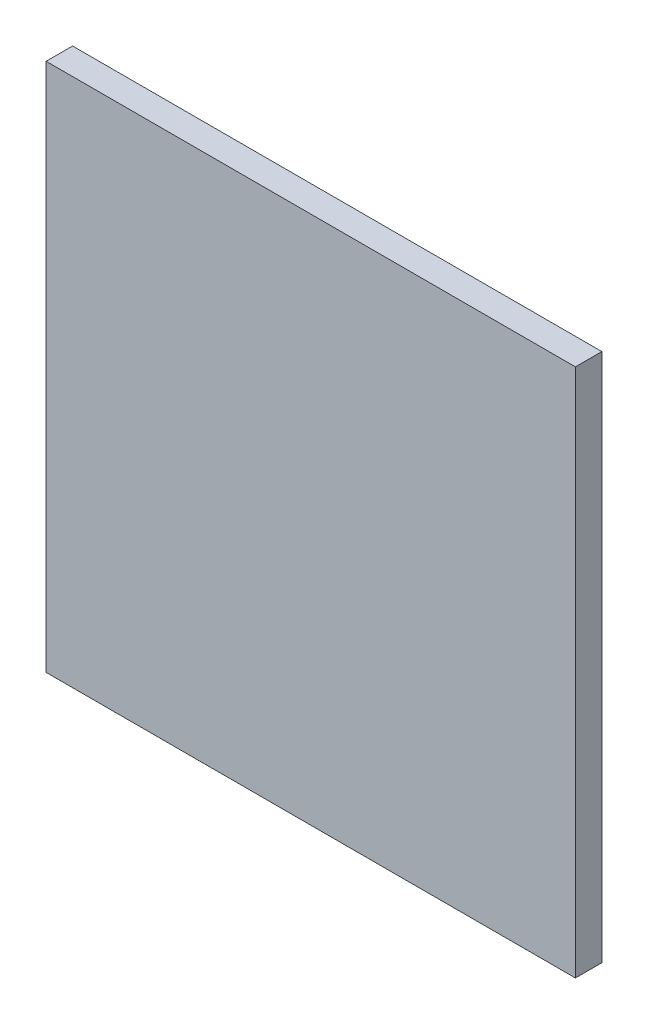
from build123d import *

# Parameters (mm, degrees)
SKETCH1_W           = 127
SKETCH1_H           = 127
BOSS_EXTRUDE1_DEPTH = 6.35


with BuildPart() as part:
    # Sketch1 → Boss-Extrude1 (new body)
    with BuildSketch(Plane(origin=(0, 0, 0), x_dir=(0, 1, 0), z_dir=(0, 0, 1))):
        with Locations((63.5, 63.5)):
            Rectangle(SKETCH1_W, SKETCH1_H)
    extrude(amount=BOSS_EXTRUDE1_DEPTH)


solid = part.part
